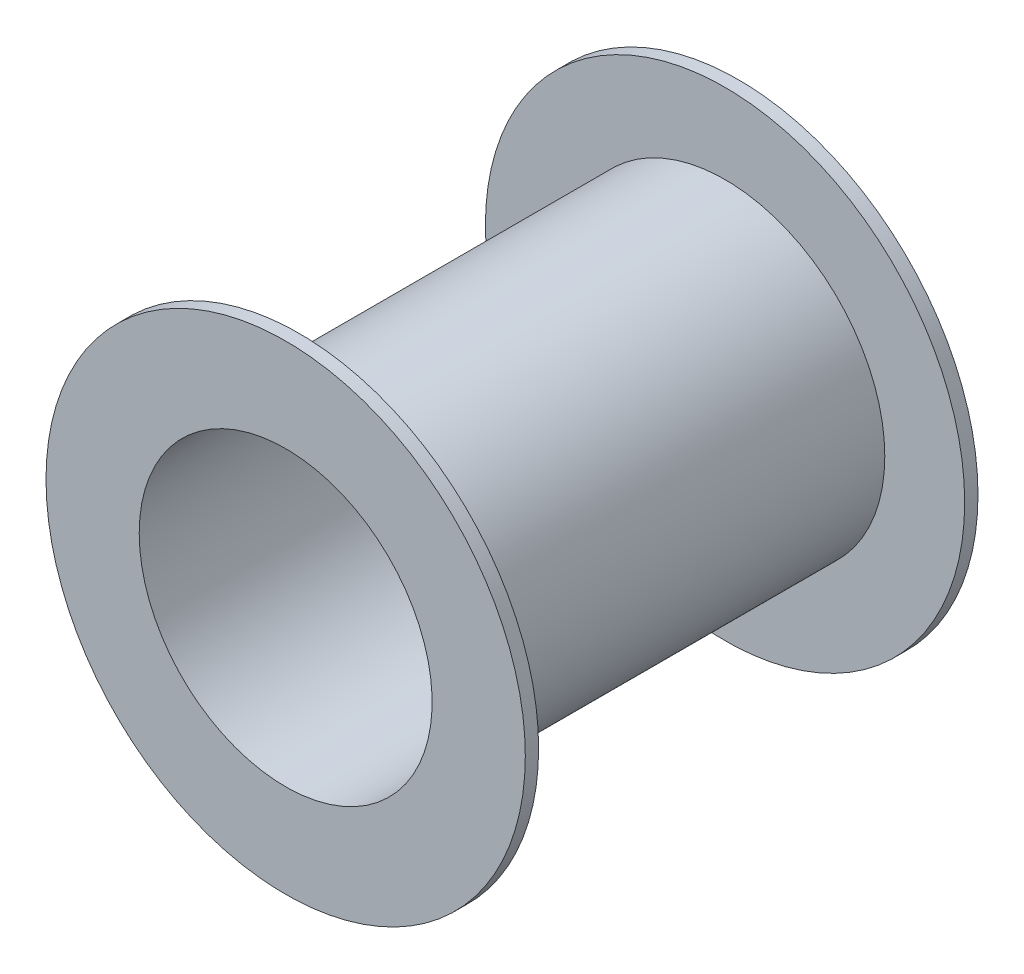
from build123d import *


with BuildPart() as part:
    # Sketch1 → Revolve1 (revolve)
    with BuildSketch(Plane(origin=(0, 0, 0), x_dir=(1, 0, 0), z_dir=(0, 1, 0))):
        Polygon((-0.55, 0.85), (-0.9, 0.85), (-0.9, 0.8), (-0.6, 0.8), (-0.6, -0.8), (-0.9, -0.8), (-0.9, -0.85), (-0.55, -0.85), align=None)
    revolve(axis=Axis((0, 0, 0), (0, 0, 1)))


solid = part.part
